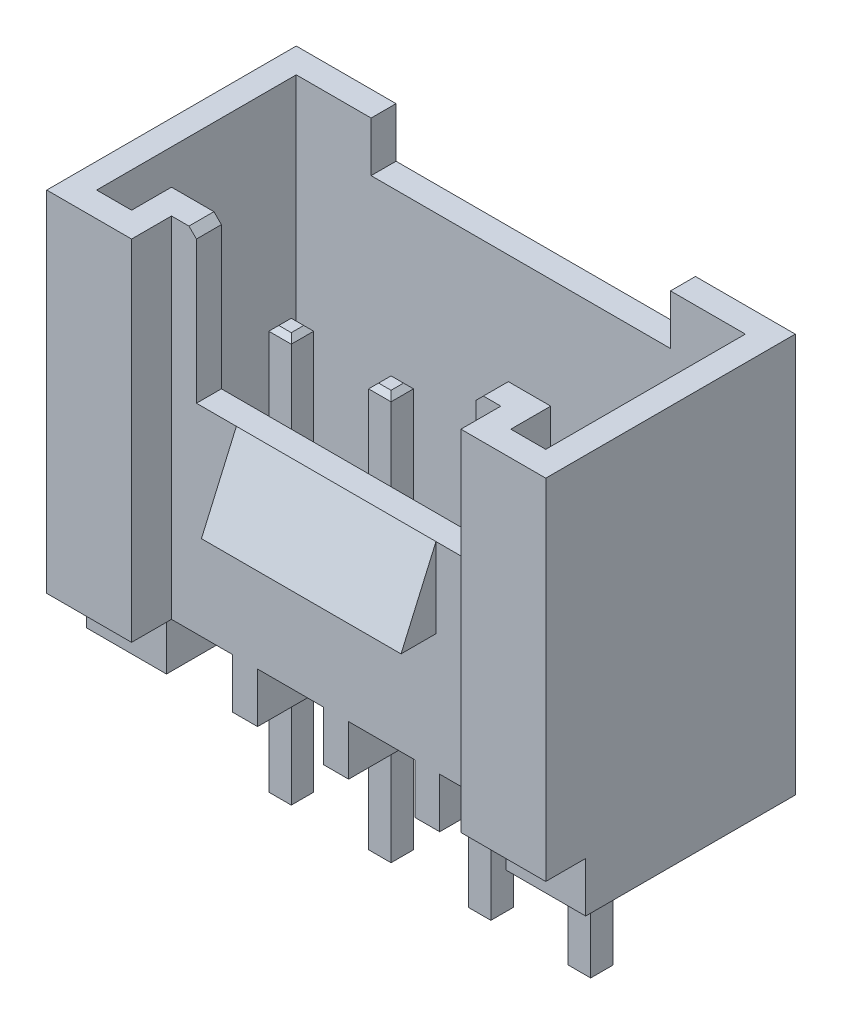
from build123d import *

# Parameters (mm, degrees)
ESQUISSE1_W             = 10
ESQUISSE1_H             = 5
BOSS_EXTRU_1_DEPTH      = 8
ESQUISSE2_W             = 6.6
ESQUISSE2_H             = 0.8
ENL_V_MAT_EXTRU_1_DEPTH = 8
ENL_V_MAT_EXTRU_2_DEPTH = 6.5
ESQUISSE5_W             = 6
ESQUISSE5_H             = 0.5
ENL_V_MAT_EXTRU_3_DEPTH = 1
ESQUISSE6_W             = 5.6
ESQUISSE6_H             = 0.5
ENL_V_MAT_EXTRU_4_DEPTH = 3
ESQUISSE7_W             = 0.8
ESQUISSE7_H             = 1
ENL_V_MAT_EXTRU_5_DEPTH = 10
ESQUISSE8_W             = 6.8
ESQUISSE8_H             = 4.2
ENL_V_MAT_EXTRU_6_DEPTH = 1
BOSS_EXTRU_2_DEPTH      = 6.8
BOSS_EXTRU_3_DEPTH      = 2
BOSS_EXTRU_3_DEPTH_BACK = 2
ESQUISSE12_W            = 0.5
ESQUISSE12_H            = 4.2
BOSS_EXTRU_4_DEPTH      = 1
CHANFREIN1_SIZE         = 0.15
ESQUISSE13_W            = 0.45
ESQUISSE13_H            = 0.45
BOSS_EXTRU_5_DEPTH      = 3.2
BOSS_EXTRU_5_DEPTH_BACK = 5
CHANFREIN2_SIZE         = 0.1


with BuildPart() as part:
    # Esquisse1 → Boss.-Extru.1 (new body)
    with BuildSketch(Plane(origin=(0, 0, 0), x_dir=(1, 0, 0), z_dir=(0, 1, 0))):
        with Locations((5, 2.5)):
            Rectangle(ESQUISSE1_W, ESQUISSE1_H)
    extrude(amount=BOSS_EXTRU_1_DEPTH)

    # Esquisse2 → Enlèv. mat.-Extru.1 (cut)
    with BuildSketch(Plane(origin=(0, 8, 0), x_dir=(1, 0, 0), z_dir=(0, 1, 0))):
        with Locations((5, 0.4)):
            Rectangle(ESQUISSE2_W, ESQUISSE2_H)
    extrude(amount=-ENL_V_MAT_EXTRU_1_DEPTH, mode=Mode.SUBTRACT)

    # Esquisse4 → Enlèv. mat.-Extru.2 (cut)
    with BuildSketch(Plane(origin=(0, 8, 0), x_dir=(1, 0, 0), z_dir=(0, 1, 0))):
        Polygon((0.5, 0.5), (1.2, 0.5), (1.2, 1.3), (8.8, 1.3), (8.8, 0.5), (9.5, 0.5), (9.5, 4.5), (0.5, 4.5), align=None)
    extrude(amount=-ENL_V_MAT_EXTRU_2_DEPTH, mode=Mode.SUBTRACT)

    # Esquisse5 → Enlèv. mat.-Extru.3 (cut)
    with BuildSketch(Plane(origin=(0, 8, 0), x_dir=(1, 0, 0), z_dir=(0, 1, 0))):
        with Locations((5, 4.75)):
            Rectangle(ESQUISSE5_W, ESQUISSE5_H)
    extrude(amount=-ENL_V_MAT_EXTRU_3_DEPTH, mode=Mode.SUBTRACT)

    # Esquisse6 → Enlèv. mat.-Extru.4 (cut)
    with BuildSketch(Plane(origin=(0, 8, 0), x_dir=(1, 0, 0), z_dir=(0, 1, 0))):
        with Locations((5, 1.05)):
            Rectangle(ESQUISSE6_W, ESQUISSE6_H)
    extrude(amount=-ENL_V_MAT_EXTRU_4_DEPTH, mode=Mode.SUBTRACT)

    # Esquisse7 → Enlèv. mat.-Extru.5 (cut)
    with BuildSketch(Plane(origin=(10, 0, 0), x_dir=(0, 0, -1), z_dir=(1, 0, 0))):
        with Locations((0.4, 0.5)):
            Rectangle(ESQUISSE7_W, ESQUISSE7_H)
    extrude(amount=-ENL_V_MAT_EXTRU_5_DEPTH, mode=Mode.SUBTRACT)

    # Esquisse8 → Enlèv. mat.-Extru.6 (cut)
    with BuildSketch(Plane.XZ):
        with Locations((5, -2.9)):
            Rectangle(ESQUISSE8_W, ESQUISSE8_H)
    extrude(amount=-ENL_V_MAT_EXTRU_6_DEPTH, mode=Mode.SUBTRACT)

    # Esquisse9 → Boss.-Extru.2 (add)
    with BuildSketch(Plane(origin=(1.6, 0, 0), x_dir=(0, 0, -1), z_dir=(1, 0, 0))):
        Polygon((4.7, 1), (3.9, 0.2), (1.9, 0.2), (1.1, 1), align=None)
    extrude(amount=BOSS_EXTRU_2_DEPTH)

    # Esquisse11 → Boss.-Extru.3 (add, two sides)
    with BuildSketch(Plane(origin=(5, 0, 0), x_dir=(0, 0, -1), z_dir=(1, 0, 0))) as boss_extru_3_sk:
        Polygon((0.8, 5), (0.1, 3.4), (0.8, 3.4), align=None)
    extrude(amount=BOSS_EXTRU_3_DEPTH)
    extrude(boss_extru_3_sk.sketch, amount=-BOSS_EXTRU_3_DEPTH_BACK)

    # Esquisse12 → Boss.-Extru.4 (add)
    with BuildSketch(Plane(origin=(0, 1, 0), x_dir=(1, 0, 0), z_dir=(0, 1, 0))):
        with Locations((5, 2.9)):
            Rectangle(ESQUISSE12_W, ESQUISSE12_H)
        with Locations((3.175, 2.9)):
            Rectangle(ESQUISSE12_W, ESQUISSE12_H)
        with Locations((6.825, 2.9)):
            Rectangle(ESQUISSE12_W, ESQUISSE12_H)
    extrude(amount=-BOSS_EXTRU_4_DEPTH)

    # Chanfrein1
    chanfrein1_edges = [part.edges().sort_by_distance(p)[0] for p in [
        (2.2, 8, -1.05),
        (7.8, 8, -1.05),
    ]]
    chamfer(chanfrein1_edges, length=CHANFREIN1_SIZE)

    # Esquisse13 → Boss.-Extru.5 (add, two sides)
    with BuildSketch(Plane.XZ.offset(-0.2)) as boss_extru_5_sk:
        with Locations((8, -2.9)):
            Rectangle(ESQUISSE13_W, ESQUISSE13_H)
        with Locations((2, -2.9)):
            Rectangle(ESQUISSE13_W, ESQUISSE13_H)
        with Locations((4, -2.9)):
            Rectangle(ESQUISSE13_W, ESQUISSE13_H)
        with Locations((6, -2.9)):
            Rectangle(ESQUISSE13_W, ESQUISSE13_H)
    extrude(amount=BOSS_EXTRU_5_DEPTH)
    extrude(boss_extru_5_sk.sketch, amount=-BOSS_EXTRU_5_DEPTH_BACK)

    # Chanfrein2
    chanfrein2_edges = [part.edges().sort_by_distance(p)[0] for p in [
        (2.225, 5.2, -2.9),
        (2, 5.2, -3.125),
        (1.775, 5.2, -2.9),
        (2, 5.2, -2.675),
        (2.225, -3, -2.9),
        (2, -3, -2.675),
        (1.775, -3, -2.9),
        (2, -3, -3.125),
        (4.225, 5.2, -2.9),
        (4, 5.2, -3.125),
        (3.775, 5.2, -2.9),
        (4, 5.2, -2.675),
        (4.225, -3, -2.9),
        (4, -3, -2.675),
        (3.775, -3, -2.9),
        (4, -3, -3.125),
        (7.775, 5.2, -2.9),
        (8, 5.2, -2.675),
        (8.225, 5.2, -2.9),
        (8, 5.2, -3.125),
        (7.775, -3, -2.9),
        (8, -3, -3.125),
        (8.225, -3, -2.9),
        (8, -3, -2.675),
        (6, 5.2, -2.675),
        (6.225, 5.2, -2.9),
        (6, 5.2, -3.125),
        (5.775, 5.2, -2.9),
        (6, -3, -2.675),
        (5.775, -3, -2.9),
        (6, -3, -3.125),
        (6.225, -3, -2.9),
    ]]
    chamfer(chanfrein2_edges, length=CHANFREIN2_SIZE)


solid = part.part
